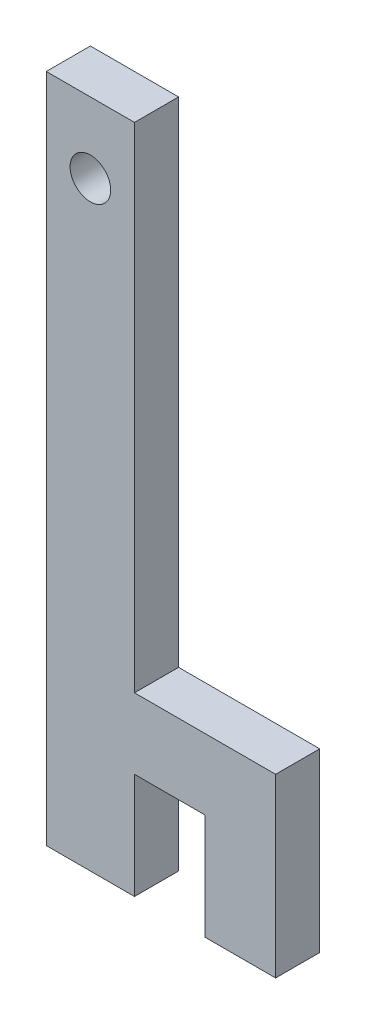
from build123d import *

# Parameters (mm, degrees)
SKETCH1_W           = 6.35
SKETCH1_H           = 48.26
BOSS_EXTRUDE1_DEPTH = 3.175
SKETCH3_R           = 1.4605
CUT_EXTRUDE2_DEPTH  = 4.175
BOSS_EXTRUDE3_DEPTH = 3.175


with BuildPart() as part:
    # Sketch1 → Boss-Extrude1 (new body)
    with BuildSketch(Plane.XY):
        with Locations((3.175, 24.13)):
            Rectangle(SKETCH1_W, SKETCH1_H)
    extrude(amount=BOSS_EXTRUDE1_DEPTH)

    # Sketch3 → Cut-Extrude2 (cut, through all)
    with BuildSketch(Plane.XY.offset(3.175)):
        with Locations((3.175, 43.18)):
            Circle(SKETCH3_R)
    extrude(amount=-CUT_EXTRUDE2_DEPTH, mode=Mode.SUBTRACT)

    # Sketch5 → Boss-Extrude3 (add)
    with BuildSketch(Plane(origin=(0, 0, 0), x_dir=(-1, 0, 0), z_dir=(0, 0, -1))):
        Polygon((-6.35, 12.7), (-16.51, 12.7), (-16.51, 0), (-11.43, 0), (-11.43, 7.62), (-6.35, 7.62), align=None)
    extrude(amount=-BOSS_EXTRUDE3_DEPTH)


solid = part.part
